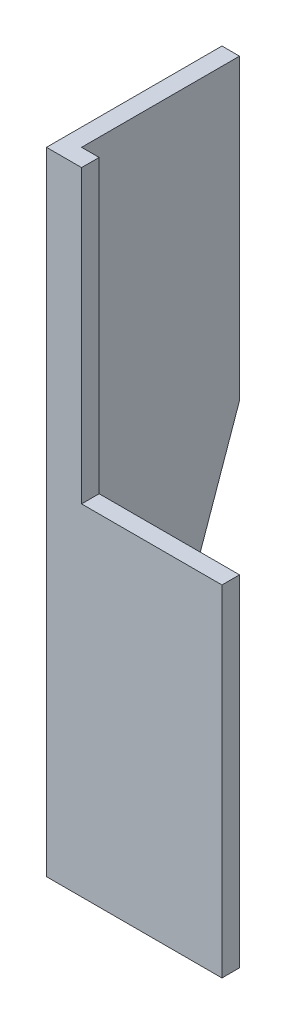
from build123d import *

# Parameters (mm, degrees)
SALIENTE_EXTRUIR1_DEPTH = 180
CORTAR_EXTRUIR1_DEPTH   = 5
CROQUIS3_W              = 40
CROQUIS3_H              = 83
CORTAR_EXTRUIR2_DEPTH   = 5


with BuildPart() as part:
    # Croquis1 → Saliente-Extruir1 (new body)
    with BuildSketch(Plane(origin=(0, 0, 0), x_dir=(1, 0, 0), z_dir=(0, 1, 0))):
        Polygon((0, 0), (0, 50), (5, 50), (5, 5), (50, 5), (50, 0), align=None)
    extrude(amount=SALIENTE_EXTRUIR1_DEPTH)

    # Croquis2 → Cortar-Extruir1 (cut)
    with BuildSketch(Plane.ZY):
        Polygon((-16.666666667, 0), (-50, 95), (-50, 0), align=None)
    extrude(amount=-CORTAR_EXTRUIR1_DEPTH, mode=Mode.SUBTRACT)

    # Croquis3 → Cortar-Extruir2 (cut)
    with BuildSketch(Plane.XY):
        with Locations((30, 138.5)):
            Rectangle(CROQUIS3_W, CROQUIS3_H)
    extrude(amount=-CORTAR_EXTRUIR2_DEPTH, mode=Mode.SUBTRACT)


solid = part.part
